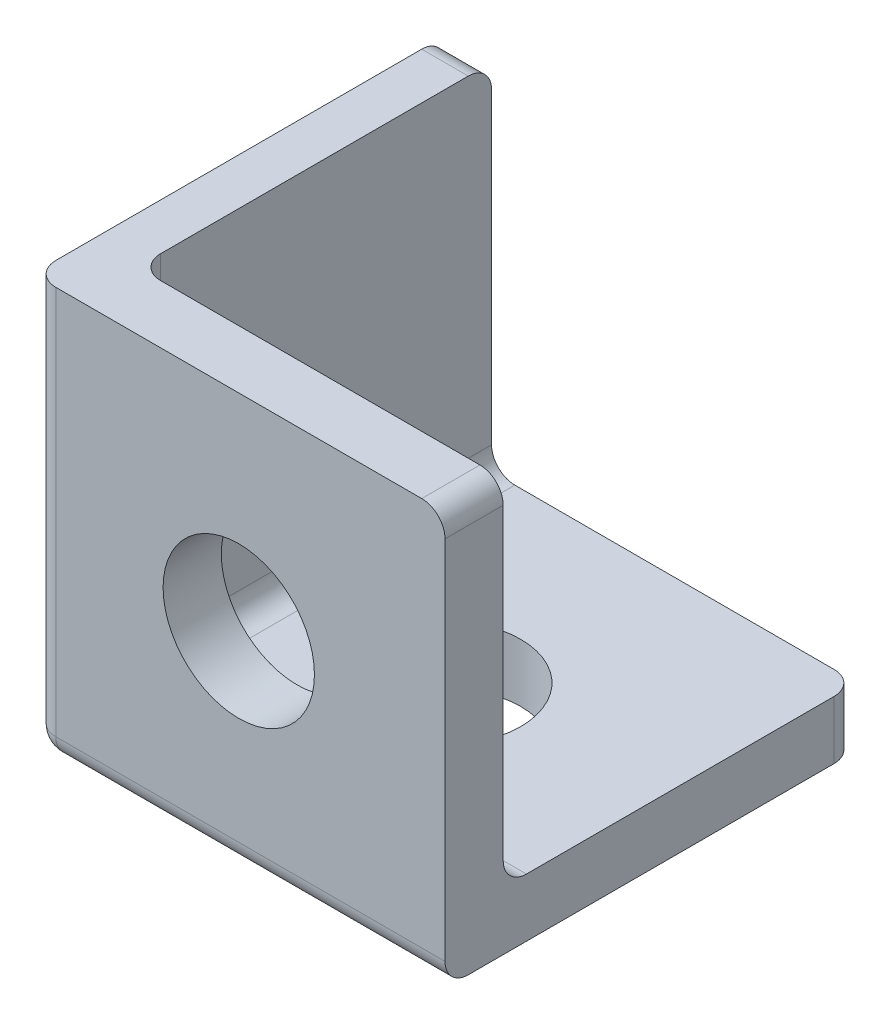
from build123d import *

# Parameters (mm, degrees)
BOSS_EXTRUDE1_DEPTH = 45
SKETCH3_R           = 8.255
CUT_EXTRUDE1_DEPTH  = 75.456849826
SKETCH2_3_W         = 38.649999916
SKETCH2_3_H         = 38.649999916
BOSS_EXTRUDE2_DEPTH = 5.08
SKETCH4_R           = 8.255
CUT_EXTRUDE2_DEPTH  = 75.456849826
FILLET1_R           = 2.54


with BuildPart() as part:
    # Sketch2 → Boss-Extrude1 (new body)
    with BuildSketch(Plane(origin=(0, 0, 0), x_dir=(0, 0, -1), z_dir=(1, 0, 0))):
        Polygon((0, 0), (44.999999916, 0), (44.999999916, 6.35), (6.35, 6.35), (6.35, 44.999999916), (0, 44.999999916), align=None)
    extrude(amount=BOSS_EXTRUDE1_DEPTH)

    # Sketch3 → Cut-Extrude1 (cut, through all)
    with BuildSketch(Plane(origin=(0, 6.35, 0), x_dir=(1, 0, 0), z_dir=(0, 1, 0))):
        with Locations((22.5, 22.499999958)):
            Circle(SKETCH3_R)
    extrude(amount=-CUT_EXTRUDE1_DEPTH, mode=Mode.SUBTRACT)

    # Sketch2_3 → Boss-Extrude2 (add)
    with BuildSketch(Plane(origin=(0, 0, 0), x_dir=(0, 0, -1), z_dir=(1, 0, 0))):
        with Locations((25.674999958, 25.674999958)):
            Rectangle(SKETCH2_3_W, SKETCH2_3_H)
    extrude(amount=BOSS_EXTRUDE2_DEPTH)

    # Sketch4 → Cut-Extrude2 (cut, through all)
    with BuildSketch(Plane(origin=(0, 0, -6.35), x_dir=(-1, 0, 0), z_dir=(0, 0, -1))):
        with Locations((-22.5, 22.499999958)):
            Circle(SKETCH4_R)
    extrude(amount=-CUT_EXTRUDE2_DEPTH, mode=Mode.SUBTRACT)

    # Fillet1
    fillet1_edges = [part.edges().sort_by_distance(p)[0] for p in [
        (45, 3.175, -44.999999916),
        (45, 44.999999916, -3.175),
        (25.04, 6.35, -6.35),
        (5.08, 6.35, -25.674999958),
        (5.08, 25.674999958, -6.35),
        (2.54, 44.999999916, -44.999999916),
        (0, 22.499999958, 0),
        (22.5, 0, 0),
        (0, 0, -22.499999958),
    ]]
    fillet(fillet1_edges, radius=FILLET1_R)


solid = part.part
